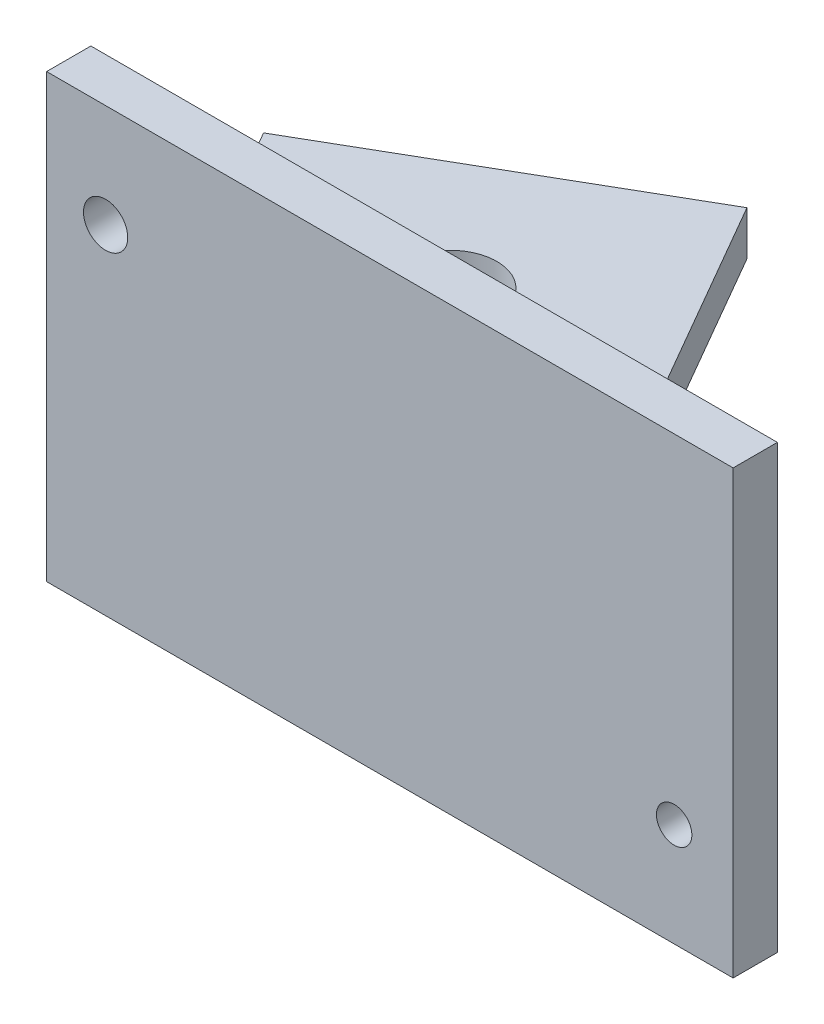
from build123d import *

# Parameters (mm, degrees)
SKETCH1_W           = 36.957
SKETCH1_H           = 21.3995
SKETCH1_R           = 1.190625
SKETCH1_R_2         = 0.9525
BOSS_EXTRUDE1_DEPTH = 2.38125
BOSS_EXTRUDE3_DEPTH = 2.38125
CUT_EXTRUDE2_REACH  = 4.381
SKETCH4_R           = 2.4892
FILLET1_R           = 2.54


with BuildPart() as part:
    # Sketch1 → Boss-Extrude1 (new body)
    with BuildSketch(Plane.XY):
        with Locations((16.891, 9.11225)):
            Rectangle(SKETCH1_W, SKETCH1_H)
        with Locations((1.5875, 14.25575)):
            Circle(SKETCH1_R, mode=Mode.SUBTRACT)
        with Locations((32.1945, 1.5875)):
            Circle(SKETCH1_R_2, mode=Mode.SUBTRACT)
    extrude(amount=BOSS_EXTRUDE1_DEPTH)

    # Sketch2 → Boss-Extrude3 (add)
    with BuildSketch(Plane.XZ.offset(1.5875)):
        Polygon((-1.5875, 2.38125), (35.3695, 2.38125), (35.3695, 0), (20.409545256, 0), (2.210283942, -31.522045256), (-14.2875, -21.997045256), (-1.5875, 0), align=None)
    extrude(amount=BOSS_EXTRUDE3_DEPTH)

    # Sketch4 → Cut-Extrude2 (cut, up to next)
    with BuildSketch(Plane(origin=(0, -1.5875, 0), x_dir=(1, 0, 0), z_dir=(0, 1, 0)), mode=Mode.PRIVATE) as cut_extrude2_sk1:
        with Locations((-2.018977372, 19.797340731)):
            Circle(SKETCH4_R)
    cut_extrude2_tool1 = extrude(cut_extrude2_sk1.sketch, amount=-CUT_EXTRUDE2_REACH, mode=Mode.PRIVATE) & part.part
    add(cut_extrude2_tool1.solids().sort_by_distance((-2.018977, -1.5875, -19.797341))[0], mode=Mode.SUBTRACT)
    # Sketch4 → Cut-Extrude2 (cut, up to next)
    with BuildSketch(Plane(origin=(0, -1.5875, 0), x_dir=(1, 0, 0), z_dir=(0, 1, 0)), mode=Mode.PRIVATE) as cut_extrude2_sk2:
        with Locations((4.331022628, 8.798818102)):
            Circle(SKETCH4_R)
    cut_extrude2_tool2 = extrude(cut_extrude2_sk2.sketch, amount=-CUT_EXTRUDE2_REACH, mode=Mode.PRIVATE) & part.part
    add(cut_extrude2_tool2.solids().sort_by_distance((4.331023, -1.5875, -8.798818))[0], mode=Mode.SUBTRACT)

    # Fillet1
    fillet1_edges = [part.edges().sort_by_distance(p)[0] for p in [
        (9.411022628, -1.5875, 0),
    ]]
    fillet(fillet1_edges, radius=FILLET1_R)


solid = part.part
